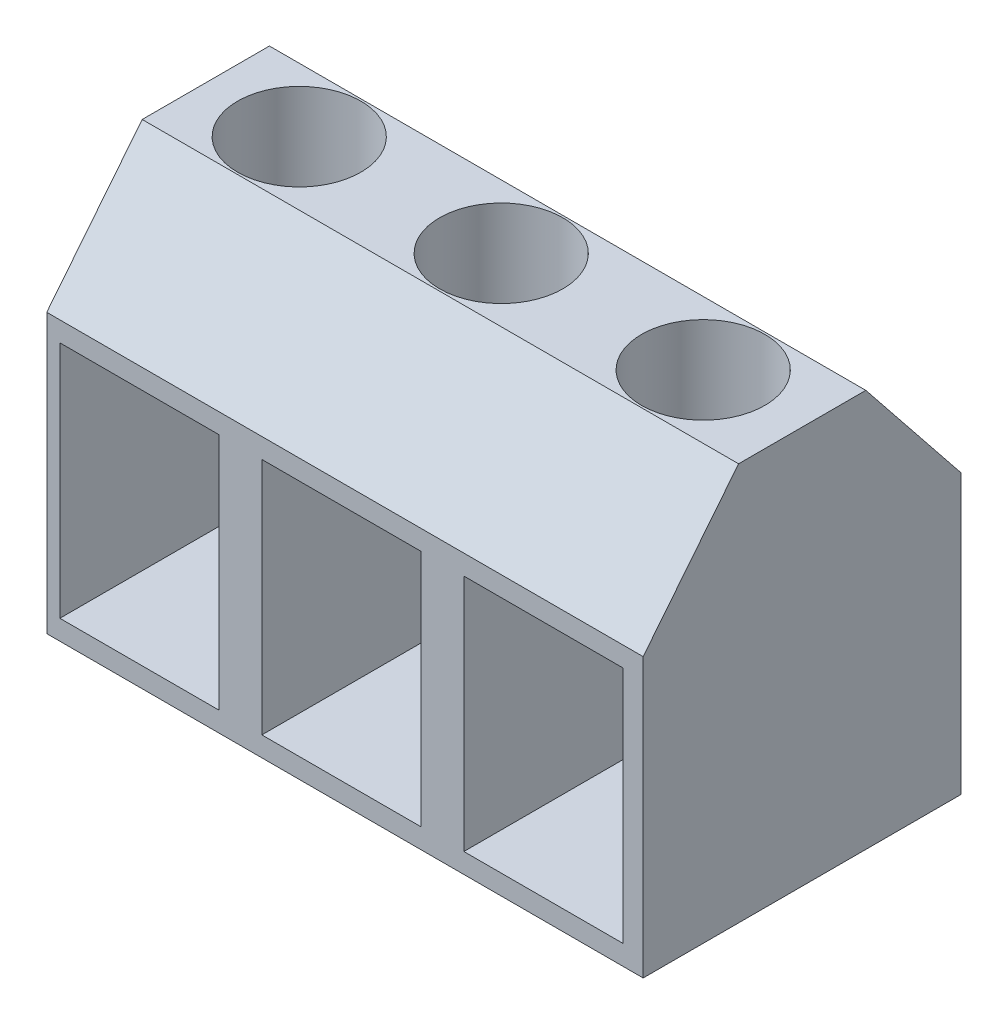
from build123d import *

# Parameters (mm, degrees)
BOSS_EXTRUDE1_DEPTH = 15
SKETCH2_W           = 4
SKETCH2_H           = 6
CUT_EXTRUDE1_DEPTH  = 7.5
SKETCH3_R           = 1.55
CUT_EXTRUDE2_DEPTH  = 3.5


with BuildPart() as part:
    # Sketch1 → Boss-Extrude1 (new body)
    with BuildSketch(Plane(origin=(0, 0, 0), x_dir=(0, 0, -1), z_dir=(1, 0, 0))):
        Polygon((-0.451016824, -0.766891322), (2.748983176, -0.766891322), (5.148983176, -3.766891322), (5.148983176, -10.766891322), (-2.851016824, -10.766891322), (-2.851016824, -3.766891322), align=None)
    extrude(amount=BOSS_EXTRUDE1_DEPTH)

    # Sketch2 → Cut-Extrude1 (cut)
    with BuildSketch(Plane.XY.offset(2.851016824)):
        with Locations((2.33, -7.266891322)):
            Rectangle(SKETCH2_W, SKETCH2_H)
        with Locations((7.41, -7.266891322)):
            Rectangle(SKETCH2_W, SKETCH2_H)
        with Locations((12.49, -7.266891322)):
            Rectangle(SKETCH2_W, SKETCH2_H)
    extrude(amount=-CUT_EXTRUDE1_DEPTH, mode=Mode.SUBTRACT)

    # Sketch3 → Cut-Extrude2 (cut)
    with BuildSketch(Plane(origin=(0, -0.766891322, 0), x_dir=(1, 0, 0), z_dir=(0, 1, 0))):
        with Locations(Location((2.35, 1.148983176, 0), (0, 0, 270))):  # turned: the seam where the file's is
            Circle(SKETCH3_R)
        with Locations(Location((7.43, 1.148983176, 0), (0, 0, 270))):  # turned: the seam where the file's is
            Circle(SKETCH3_R)
        with Locations(Location((12.51, 1.148983176, 0), (0, 0, 270))):  # turned: the seam where the file's is
            Circle(SKETCH3_R)
    extrude(amount=-CUT_EXTRUDE2_DEPTH, mode=Mode.SUBTRACT)


solid = part.part
